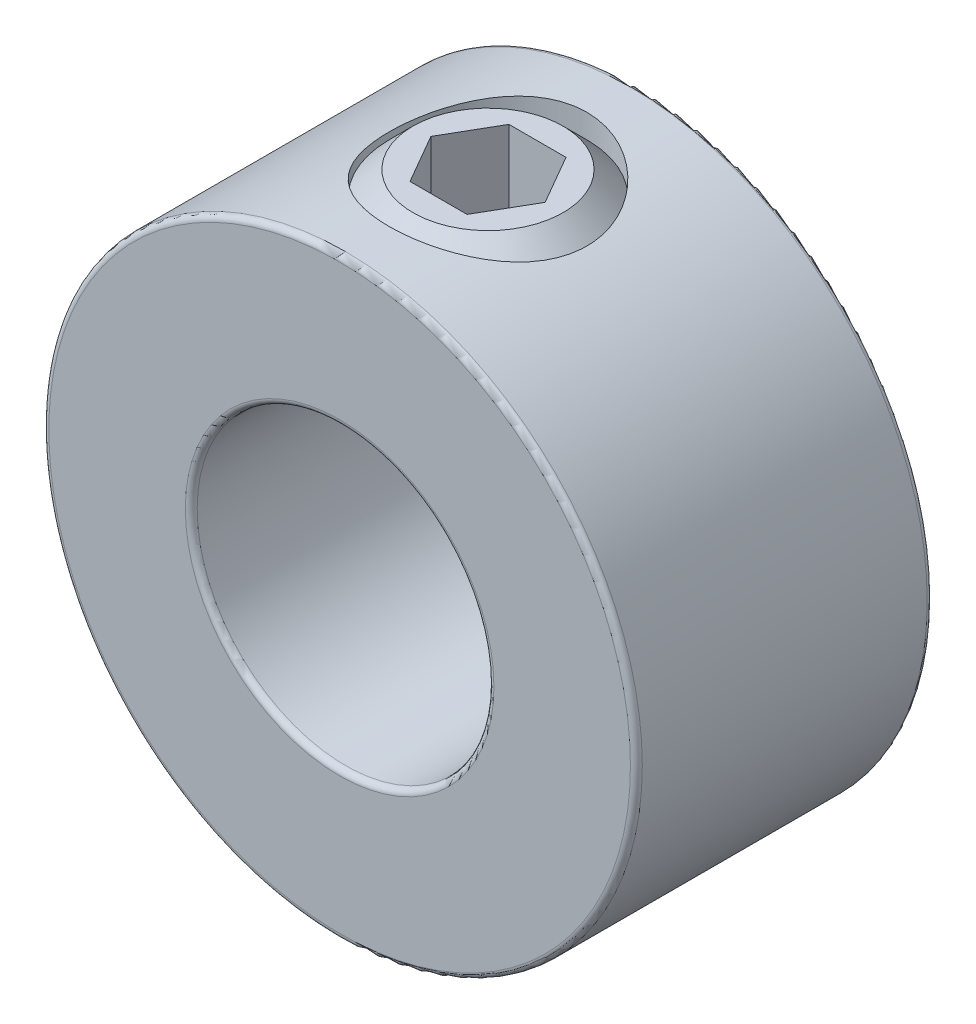
from build123d import *

# Parameters (mm, degrees)
SKETCH1_R          = 9.525
SKETCH1_R_2        = 4.7625
EXTRUDE1_DEPTH     = 4.7625
SKETCH2_R          = 3.175
CUT_EXTRUDE1_DEPTH = 10.525
FILLET1_R          = 0.1905
CUT_EXTRUDE2_DEPTH = 3.175


with BuildPart() as part:
    # Sketch1 → Extrude1 (new body, symmetric)
    with BuildSketch(Plane.XY):
        Circle(SKETCH1_R)
        Circle(SKETCH1_R_2, mode=Mode.SUBTRACT)
    extrude(amount=EXTRUDE1_DEPTH, both=True)

    # Sketch2 → Cut-Extrude1 (cut, through all)
    with BuildSketch(Plane(origin=(41.275, 0, 0), x_dir=(0, 0, -1), z_dir=(0, -1, 0))):
        with Locations((0, -41.275)):
            Circle(SKETCH2_R)
    extrude(amount=-CUT_EXTRUDE1_DEPTH, mode=Mode.SUBTRACT)

    # Fillet1
    fillet1_edges = [part.edges().sort_by_distance(p)[0] for p in [
        (-9.525, 0, -4.7625),
        (-9.525, 0, 4.7625),
        (-4.7625, 0, -4.7625),
        (-4.7625, 0, 4.7625),
    ]]
    fillet(fillet1_edges, radius=FILLET1_R)


with BuildPart() as body_2:
    # Sketch3 → Revolve1 (revolve)
    with BuildSketch(Plane.XY):
        Polygon((-2.408192631, 4.7625), (-0.920168843, 4.7625), (0, 5.682668843), (0, 9.525), (-2.408192631, 9.525), (-3.175, 8.758192631), (-3.175, 5.529307369), align=None)
    revolve(axis=Axis((0, 4.7625, 0), (0, -1, 0)))

    # Sketch4 → Cut-Extrude2 (cut)
    with BuildSketch(Plane(origin=(3.3734375, 9.525, 0), x_dir=(0, 0, -1), z_dir=(0, -1, 0))):
        Polygon((0, -1.540350395), (-1.5875, -2.456893948), (-1.5875, -4.289981052), (0, -5.206524605), (1.5875, -4.289981052), (1.5875, -2.456893948), align=None)
    extrude(amount=CUT_EXTRUDE2_DEPTH, mode=Mode.SUBTRACT)


solid = Compound([part.part, body_2.part])
